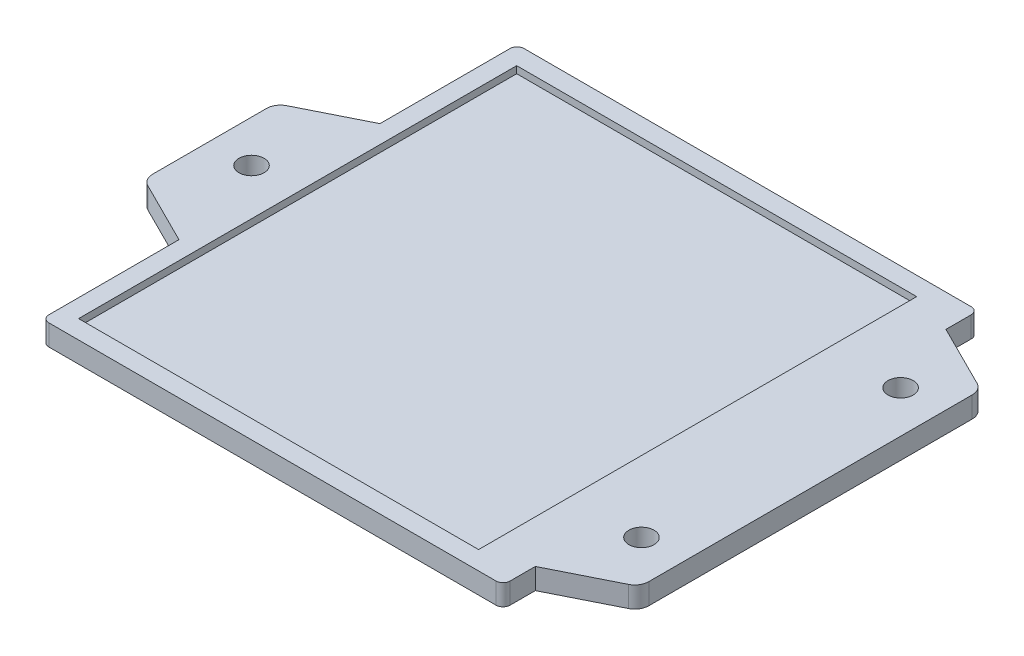
from build123d import *

# Parameters (mm, degrees)
SKETCH1_R           = 1.8
BOSS_EXTRUDE1_DEPTH = 3
CUT_EXTRUDE1_START  = 3
SKETCH3_W           = 57.25
SKETCH3_H           = 62.7
CUT_EXTRUDE1_DEPTH  = 1


with BuildPart() as part:
    # Sketch1 → Boss-Extrude1 (new body)
    with BuildSketch(Plane(origin=(0, 0, 0), x_dir=(-1, 0, 0), z_dir=(0, 1, 0))):
        with BuildLine():
            Line((-33, 29.381966011), (-33, 33))
            ThreePointArc((-33, 33), (-32.707106781, 33.707106781), (-32, 34))
            Line((-32, 34), (32, 34))
            ThreePointArc((32, 34), (32.707106781, 33.707106781), (33, 33))
            Line((33, 33), (33, 14.381966011))
            Line((33, 14.381966011), (41.894427191, 9.934752416))
            ThreePointArc((41.894427191, 9.934752416), (42.701301617, 9.197360258), (43, 8.145898034))
            Line((43, 8.145898034), (43, -8.145898034))
            ThreePointArc((43, -8.145898034), (42.701301617, -9.197360258), (41.894427191, -9.934752416))
            Line((41.894427191, -9.934752416), (33, -14.381966011))
            Line((33, -14.381966011), (33, -33))
            ThreePointArc((33, -33), (32.707106781, -33.707106781), (32, -34))
            Line((32, -34), (-32, -34))
            ThreePointArc((-32, -34), (-32.707106781, -33.707106781), (-33, -33))
            Line((-33, -33), (-33, -29.381966011))
            Line((-33, -29.381966011), (-41.894427191, -24.934752416))
            ThreePointArc((-41.894427191, -24.934752416), (-42.701301617, -24.197360258), (-43, -23.145898034))
            Line((-43, -23.145898034), (-43, 23.145898034))
            ThreePointArc((-43, 23.145898034), (-42.701301617, 24.197360258), (-41.894427191, 24.934752416))
            Line((-41.894427191, 24.934752416), (-33, 29.381966011))
        make_face()
        with Locations((-37, 18.192906379)):
            Circle(SKETCH1_R, mode=Mode.SUBTRACT)
        with Locations((-37, -18.896413475)):
            Circle(SKETCH1_R, mode=Mode.SUBTRACT)
        with Locations((37, 0)):
            Circle(SKETCH1_R, mode=Mode.SUBTRACT)
    extrude(amount=BOSS_EXTRUDE1_DEPTH)

    # Sketch3 → Cut-Extrude1 (cut)
    with BuildSketch(Plane(origin=(0, 0, 0), x_dir=(-1, 0, 0), z_dir=(0, 1, 0)).offset(CUT_EXTRUDE1_START)):
        with Locations((1.775, 0)):
            Rectangle(SKETCH3_W, SKETCH3_H)
    extrude(amount=-CUT_EXTRUDE1_DEPTH, mode=Mode.SUBTRACT)


solid = part.part
